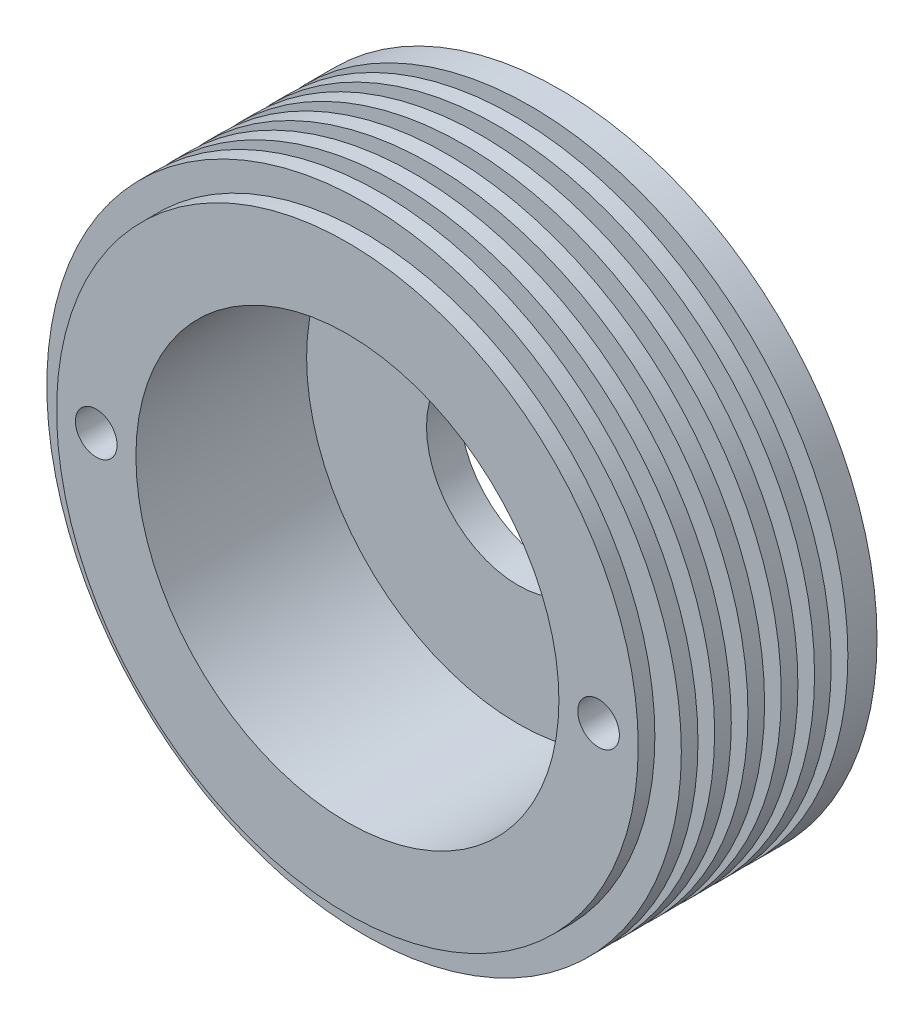
from build123d import *

# Parameters (mm, degrees)
ESQUISSE1_R                = 38.1
BOSS_EXTRU_1_DEPTH         = 25.5
ESQUISSE3_R                = 25.4
ENL_V_MAT_EXTRU_2_DEPTH    = 20.5
ESQUISSE5_R                = 11
ENL_V_MAT_EXTRU_3_DEPTH    = 5
ESQUISSE7_R                = 12.7
ENL_V_MAT_EXTRU_4_DEPTH    = 1
ESQUISSE8_R                = 38.1
ESQUISSE8_R_2              = 34.925
ENL_V_MAT_EXTRU_5_DEPTH    = 2
R_P_TITION_LIN_AIRE1_COUNT = 6
R_P_TITION_LIN_AIRE1_PITCH = 4
ESQUISSE9_R                = 2.5
ENL_V_MAT_EXTRU_6_DEPTH    = 26.5


with BuildPart() as part:
    # Esquisse1 → Boss.-Extru.1 (new body)
    with BuildSketch(Plane.XY):
        with Locations((23.679503876, 29.670703652)):
            Circle(ESQUISSE1_R)
    extrude(amount=BOSS_EXTRU_1_DEPTH)

    # Esquisse3 → Enlèv. mat.-Extru.2 (cut)
    with BuildSketch(Plane.XY.offset(25.5)):
        with Locations((23.679503876, 29.670703652)):
            Circle(ESQUISSE3_R)
    extrude(amount=-ENL_V_MAT_EXTRU_2_DEPTH, mode=Mode.SUBTRACT)

    # Esquisse5 → Enlèv. mat.-Extru.3 (cut)
    with BuildSketch(Plane(origin=(0, 0, 0), x_dir=(-1, 0, 0), z_dir=(0, 0, -1))):
        with Locations((-23.679503876, 29.670703652)):
            Circle(ESQUISSE5_R)
    extrude(amount=-ENL_V_MAT_EXTRU_3_DEPTH, mode=Mode.SUBTRACT)

    # Esquisse7 → Enlèv. mat.-Extru.4 (cut)
    with BuildSketch(Plane(origin=(0, 0, 0), x_dir=(-1, 0, 0), z_dir=(0, 0, -1))):
        with Locations((-23.679503876, 29.670703652)):
            Circle(ESQUISSE7_R)
    extrude(amount=-ENL_V_MAT_EXTRU_4_DEPTH, mode=Mode.SUBTRACT)

    # Esquisse8 → Enlèv. mat.-Extru.5 (cut)
    with BuildSketch(Plane.XY.offset(25.5)):
        with Locations((23.679503876, 29.670703652)):
            Circle(ESQUISSE8_R)
        with Locations((23.679503876, 29.670703652)):
            Circle(ESQUISSE8_R_2, mode=Mode.SUBTRACT)
    enl_v_mat_extru_5 = extrude(amount=-ENL_V_MAT_EXTRU_5_DEPTH, mode=Mode.SUBTRACT)

    # Répétition linéaire1: Enlèv. mat.-Extru.5 ×6
    with Locations(*[(0, 0, -i * R_P_TITION_LIN_AIRE1_PITCH) for i in range(1, R_P_TITION_LIN_AIRE1_COUNT)]):
        add(enl_v_mat_extru_5, mode=Mode.SUBTRACT)

    # Esquisse9 → Enlèv. mat.-Extru.6 (cut, through all)
    with BuildSketch(Plane(origin=(0, 0, 0), x_dir=(-1, 0, 0), z_dir=(0, 0, -1))):
        with Locations((6.482996124, 29.670703652)):
            Circle(ESQUISSE9_R)
        with Locations((-53.842003876, 29.670703652)):
            Circle(ESQUISSE9_R)
    extrude(amount=-ENL_V_MAT_EXTRU_6_DEPTH, mode=Mode.SUBTRACT)


solid = part.part
